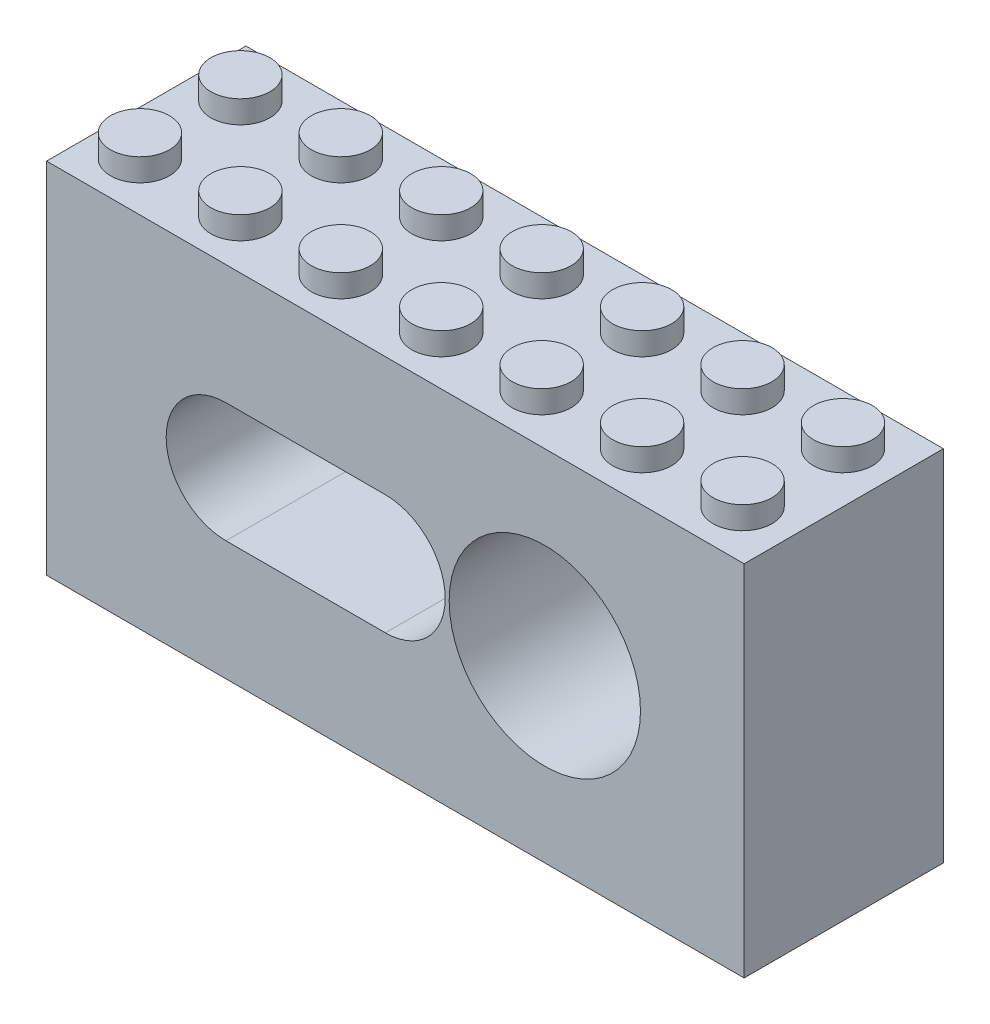
from build123d import *

# Parameters (mm, degrees)
SKETCH1_W           = 55.5625
SKETCH1_H           = 31.75
BOSS_EXTRUDE1_DEPTH = 28.575
SKETCH2_R           = 7.62
CUT_EXTRUDE1_DEPTH  = 13.335
CUT_EXTRUDE2_DEPTH  = 12.7
SKETCH4_R           = 1.8415
CUT_EXTRUDE3_DEPTH  = 25.4
CUT_EXTRUDE4_DEPTH  = 17.78
SKETCH6_W           = 55.5625
SKETCH6_H           = 28.575
CUT_EXTRUDE5_DEPTH  = 15.875
SKETCH7_R           = 2.778125
CUT_EXTRUDE7_DEPTH  = 7.9375
SKETCH8_R           = 2.35
BOSS_EXTRUDE2_DEPTH = 1.8
SKETCH9_R           = 3.25
SKETCH9_R_2         = 2.425
CUT_EXTRUDE8_DEPTH  = 2.1


with BuildPart() as part:
    # Sketch1 → Boss-Extrude1 (new body)
    with BuildSketch(Plane(origin=(0, 0, 0), x_dir=(1, 0, 0), z_dir=(0, 1, 0))):
        with Locations((-66.667749699, 35.16562105)):
            Rectangle(SKETCH1_W, SKETCH1_H)
    extrude(amount=BOSS_EXTRUDE1_DEPTH)

    # Sketch2 → Cut-Extrude1 (cut)
    with BuildSketch(Plane.XY.offset(-19.29062105)):
        with Locations((-54.761499699, 14.2875)):
            Circle(SKETCH2_R)
    extrude(amount=-CUT_EXTRUDE1_DEPTH, mode=Mode.SUBTRACT)

    # Sketch3 → Cut-Extrude2 (cut)
    with BuildSketch(Plane.XY.offset(-19.29062105)):
        with BuildLine():
            Line((-80.161499699, 19.05), (-67.461499699, 19.05))
            ThreePointArc((-67.461499699, 19.05), (-62.698999699, 14.2875), (-67.461499699, 9.525))
            Line((-67.461499699, 9.525), (-80.161499699, 9.525))
            ThreePointArc((-80.161499699, 9.525), (-84.923999699, 14.2875), (-80.161499699, 19.05))
        make_face()
    extrude(amount=-CUT_EXTRUDE2_DEPTH, mode=Mode.SUBTRACT)

    # Sketch4 → Cut-Extrude3 (cut)
    with BuildSketch(Plane.XY.offset(-31.99062105)):
        with Locations((-80.161499699, 14.2875)):
            Circle(SKETCH4_R)
        with Locations((-67.461499699, 14.2875)):
            Circle(SKETCH4_R)
    extrude(amount=-CUT_EXTRUDE3_DEPTH, mode=Mode.SUBTRACT)

    # Sketch5 → Cut-Extrude4 (cut)
    with BuildSketch(Plane(origin=(0, 0, -51.04062105), x_dir=(-1, 0, 0), z_dir=(0, 0, -1))):
        with BuildLine():
            Line((67.461499699, 9.525), (80.161499699, 9.525))
            ThreePointArc((80.161499699, 9.525), (84.923999699, 14.2875), (80.161499699, 19.05))
            Line((80.161499699, 19.05), (67.461499699, 19.05))
            ThreePointArc((67.461499699, 19.05), (62.698999699, 14.2875), (67.461499699, 9.525))
        make_face()
    extrude(amount=-CUT_EXTRUDE4_DEPTH, mode=Mode.SUBTRACT)

    # Sketch6 → Cut-Extrude5 (cut)
    with BuildSketch(Plane(origin=(0, 0, -51.04062105), x_dir=(-1, 0, 0), z_dir=(0, 0, -1))):
        with Locations((66.667749699, 14.2875)):
            Rectangle(SKETCH6_W, SKETCH6_H)
    extrude(amount=-CUT_EXTRUDE5_DEPTH, mode=Mode.SUBTRACT)

    # Sketch7 → Cut-Extrude7 (cut)
    with BuildSketch(Plane.XY.offset(-32.62562105)):
        with Locations((-54.761499699, 14.2875)):
            Circle(SKETCH7_R)
    extrude(amount=-CUT_EXTRUDE7_DEPTH, mode=Mode.SUBTRACT)

    # Sketch8 → Boss-Extrude2 (add)
    with BuildSketch(Plane(origin=(0, 28.575, 0), x_dir=(1, 0, 0), z_dir=(0, 1, 0))):
        with Locations((-42.886499699, 31.16562105)):
            Circle(SKETCH8_R)
        with Locations((-42.886499699, 23.16562105)):
            Circle(SKETCH8_R)
        with Locations((-50.886499699, 31.16562105)):
            Circle(SKETCH8_R)
        with Locations((-50.886499699, 23.16562105)):
            Circle(SKETCH8_R)
        with Locations((-58.886499699, 31.16562105)):
            Circle(SKETCH8_R)
        with Locations((-58.886499699, 23.16562105)):
            Circle(SKETCH8_R)
        with Locations((-66.886499699, 31.16562105)):
            Circle(SKETCH8_R)
        with Locations((-66.886499699, 23.16562105)):
            Circle(SKETCH8_R)
        with Locations((-74.886499699, 31.16562105)):
            Circle(SKETCH8_R)
        with Locations((-74.886499699, 23.16562105)):
            Circle(SKETCH8_R)
        with Locations((-82.886499699, 31.16562105)):
            Circle(SKETCH8_R)
        with Locations((-82.886499699, 23.16562105)):
            Circle(SKETCH8_R)
        with Locations((-90.886499699, 31.16562105)):
            Circle(SKETCH8_R)
        with Locations((-90.886499699, 23.16562105)):
            Circle(SKETCH8_R)
    extrude(amount=BOSS_EXTRUDE2_DEPTH)

    # Sketch9 → Cut-Extrude8 (cut)
    with BuildSketch(Plane.XZ):
        Polygon((-82.874999699, -20.79062105), (-82.874999699, -20.49062105), (-90.148999699, -20.49062105), (-90.148999699, -20.79062105), (-90.748999699, -20.79062105), (-90.748999699, -20.49062105), (-93.248999699, -20.49062105), (-93.248999699, -22.99062105), (-92.948999699, -22.99062105), (-92.948999699, -23.59062105), (-93.248999699, -23.59062105), (-93.248999699, -30.99062105), (-92.948999699, -30.99062105), (-92.948999699, -31.59062105), (-93.248999699, -31.59062105), (-93.248999699, -33.96562105), (-90.748999699, -33.96562105), (-90.748999699, -33.66562105), (-90.148999699, -33.66562105), (-90.148999699, -33.96562105), (-82.874999699, -33.96562105), (-82.874999699, -33.66562105), (-82.274999699, -33.66562105), (-82.274999699, -33.96562105), (-75.000999699, -33.96562105), (-75.000999699, -33.66562105), (-74.400999699, -33.66562105), (-74.400999699, -33.96562105), (-67.126999699, -33.96562105), (-67.126999699, -33.66562105), (-66.526999699, -33.66562105), (-66.526999699, -33.96562105), (-59.252999699, -33.96562105), (-59.252999699, -33.66562105), (-58.652999699, -33.66562105), (-58.652999699, -33.96562105), (-51.378999699, -33.96562105), (-51.378999699, -33.66562105), (-50.778999699, -33.66562105), (-50.778999699, -33.96562105), (-43.504999699, -33.96562105), (-43.504999699, -33.66562105), (-42.904999699, -33.66562105), (-42.904999699, -33.96562105), (-40.086499699, -33.96562105), (-40.086499699, -20.49062105), (-42.904999699, -20.49062105), (-42.904999699, -20.79062105), (-43.504999699, -20.79062105), (-43.504999699, -20.49062105), (-50.778999699, -20.49062105), (-50.778999699, -20.79062105), (-51.378999699, -20.79062105), (-51.378999699, -20.49062105), (-58.652999699, -20.49062105), (-58.652999699, -20.79062105), (-59.252999699, -20.79062105), (-59.252999699, -20.49062105), (-66.526999699, -20.49062105), (-66.526999699, -20.79062105), (-67.126999699, -20.79062105), (-67.126999699, -20.49062105), (-74.400999699, -20.49062105), (-74.400999699, -20.79062105), (-75.000999699, -20.79062105), (-75.000999699, -20.49062105), (-82.274999699, -20.49062105), (-82.274999699, -20.79062105), align=None)
        with Locations((-86.886499699, -27.29062105)):
            Circle(SKETCH9_R, mode=Mode.SUBTRACT)
        with Locations((-78.886499699, -27.29062105)):
            Circle(SKETCH9_R, mode=Mode.SUBTRACT)
        with Locations((-70.886499699, -27.29062105)):
            Circle(SKETCH9_R, mode=Mode.SUBTRACT)
        with Locations((-62.886499699, -27.29062105)):
            Circle(SKETCH9_R, mode=Mode.SUBTRACT)
        with Locations((-54.886499699, -27.29062105)):
            Circle(SKETCH9_R, mode=Mode.SUBTRACT)
        with Locations((-46.886499699, -27.29062105)):
            Circle(SKETCH9_R, mode=Mode.SUBTRACT)
        with Locations((-46.886499699, -27.29062105)):
            Circle(SKETCH9_R_2)
        with Locations((-54.886499699, -27.29062105)):
            Circle(SKETCH9_R_2)
        with Locations((-62.886499699, -27.29062105)):
            Circle(SKETCH9_R_2)
        with Locations((-70.886499699, -27.29062105)):
            Circle(SKETCH9_R_2)
        with Locations((-78.886499699, -27.29062105)):
            Circle(SKETCH9_R_2)
        with Locations((-86.886499699, -27.29062105)):
            Circle(SKETCH9_R_2)
    extrude(amount=-CUT_EXTRUDE8_DEPTH, mode=Mode.SUBTRACT)


solid = part.part
